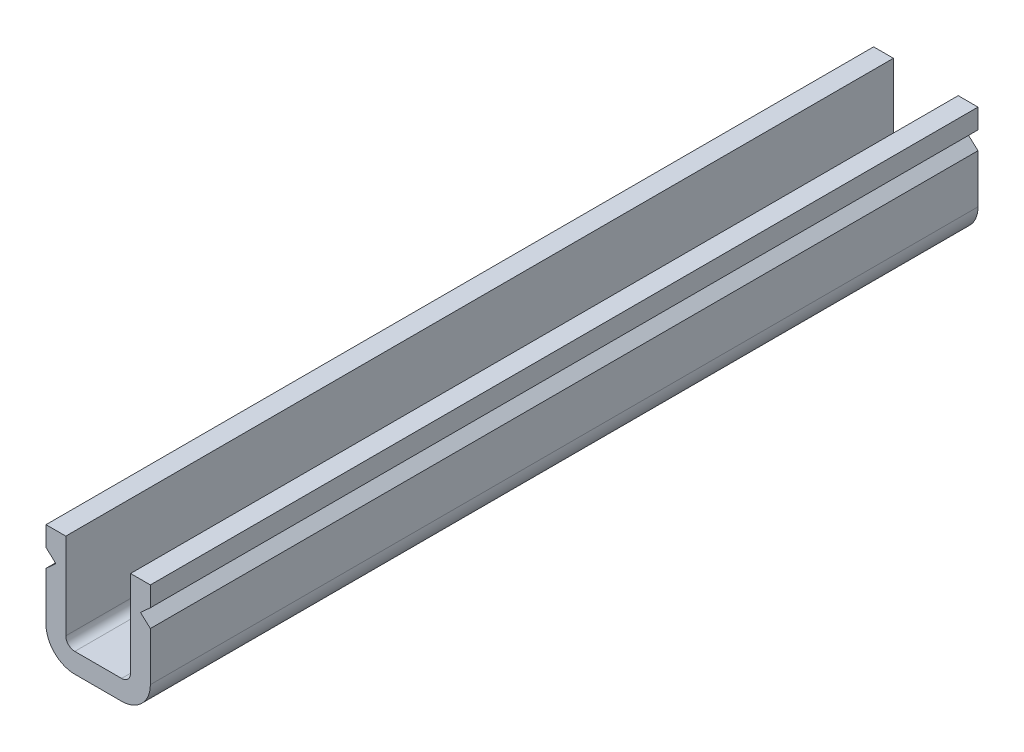
from build123d import *

# Parameters (mm, degrees)
EXTRUSION1_DEPTH = 46


with BuildPart() as part:
    # Esquisse1 → Extrusion1 (new body)
    with BuildSketch(Plane.XY):
        with BuildLine():
            Line((4.7, -4.8), (4.7, 0))
            Line((4.7, 0), (5.8, 0))
            Line((5.8, 0), (5.8, -1.1))
            Line((5.8, -1.1), (5.25, -1.6))
            Line((5.25, -1.6), (5.8, -2.1))
            Line((5.8, -2.1), (5.8, -4.8))
            ThreePointArc((5.8, -4.8), (5.33137085, -5.93137085), (4.2, -6.4))
            Line((4.2, -6.4), (1.6, -6.4))
            ThreePointArc((1.6, -6.4), (0.46862915, -5.93137085), (0, -4.8))
            Line((0, -4.8), (0, -2.1))
            Line((0, -2.1), (0.55, -1.6))
            Line((0.55, -1.6), (0, -1.1))
            Line((0, -1.1), (0, 0))
            Line((0, 0), (1.1, 0))
            Line((1.1, 0), (1.1, -4.8))
            ThreePointArc((1.1, -4.8), (1.246446609, -5.153553391), (1.6, -5.3))
            Line((1.6, -5.3), (4.2, -5.3))
            ThreePointArc((4.2, -5.3), (4.553553391, -5.153553391), (4.7, -4.8))
        make_face()
    extrude(amount=EXTRUSION1_DEPTH)


solid = part.part
